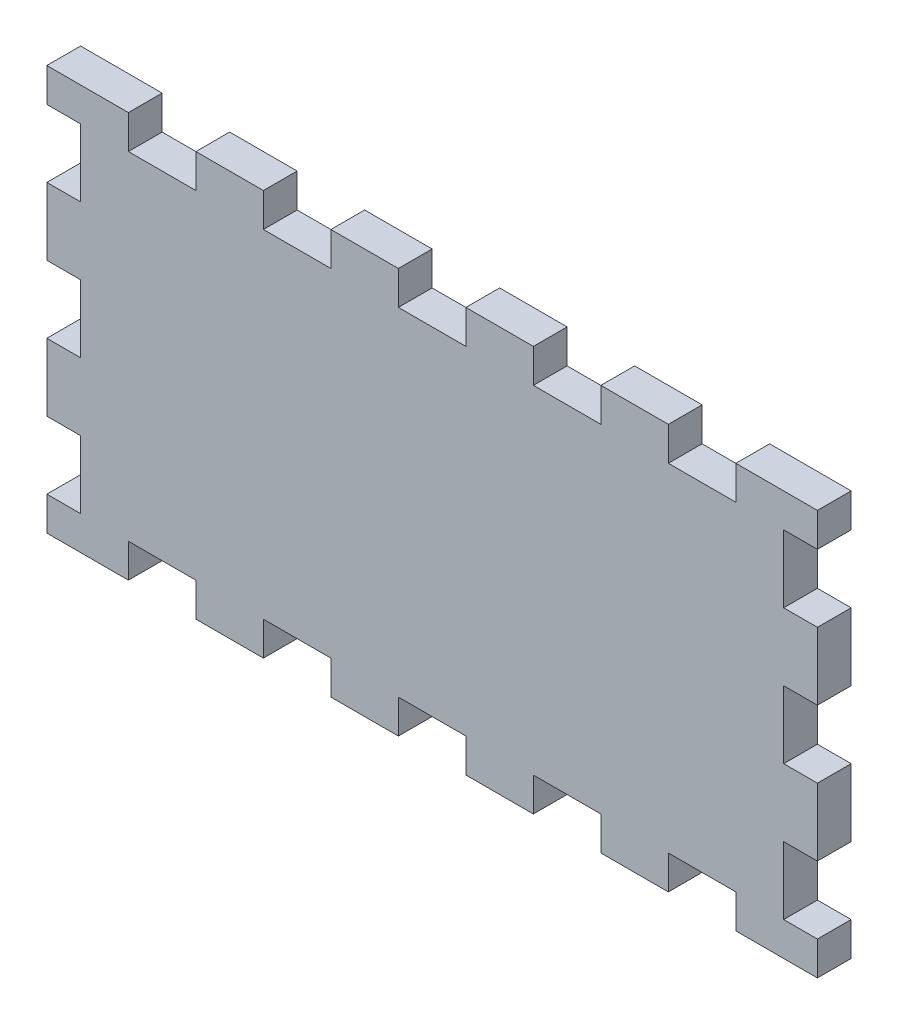
from build123d import *

# Parameters (mm, degrees)
SKETCH2_W           = 8.5
SKETCH2_H           = 6
BOSS_EXTRUDE1_DEPTH = 6
SKETCH3_W           = 6
SKETCH3_H           = 12
CUT_EXTRUDE1_DEPTH  = 6


with BuildPart() as part:
    # Sketch2 → Boss-Extrude1 (new body)
    with BuildSketch(Plane.XY):
        with Locations((-58.25, 3)):
            Rectangle(SKETCH2_W, SKETCH2_H)
        Polygon((-68.5, 72), (-68.5, 0), (-62.5, 0), (-62.5, 6), (-54, 6), (-42, 6), (-42, 0), (-30, 0), (-30, 6), (-18, 6), (-18, 0), (-6, 0), (-6, 6), (6, 6), (6, 0), (18, 0), (18, 6), (30, 6), (30, 0), (42, 0), (42, 6), (54, 6), (54, 0), (68.5, 0), (68.5, 72), (54, 72), (54, 66), (42, 66), (42, 72), (30, 72), (30, 66), (18, 66), (18, 72), (6, 72), (6, 66), (-6, 66), (-6, 72), (-18, 72), (-18, 66), (-30, 66), (-30, 72), (-42, 72), (-42, 66), (-54, 66), (-54, 72), align=None)
    extrude(amount=BOSS_EXTRUDE1_DEPTH)

    # Sketch3 → Cut-Extrude1 (cut)
    with BuildSketch(Plane.XY.offset(6)):
        with Locations((-65.5, 60)):
            Rectangle(SKETCH3_W, SKETCH3_H)
        with Locations((-65.5, 12)):
            Rectangle(SKETCH3_W, SKETCH3_H)
        with Locations((65.5, 36)):
            Rectangle(SKETCH3_W, SKETCH3_H)
        with Locations((65.5, 12)):
            Rectangle(SKETCH3_W, SKETCH3_H)
        with Locations((-65.5, 36)):
            Rectangle(SKETCH3_W, SKETCH3_H)
        with Locations((65.5, 60)):
            Rectangle(SKETCH3_W, SKETCH3_H)
    extrude(amount=-CUT_EXTRUDE1_DEPTH, mode=Mode.SUBTRACT)


solid = part.part
